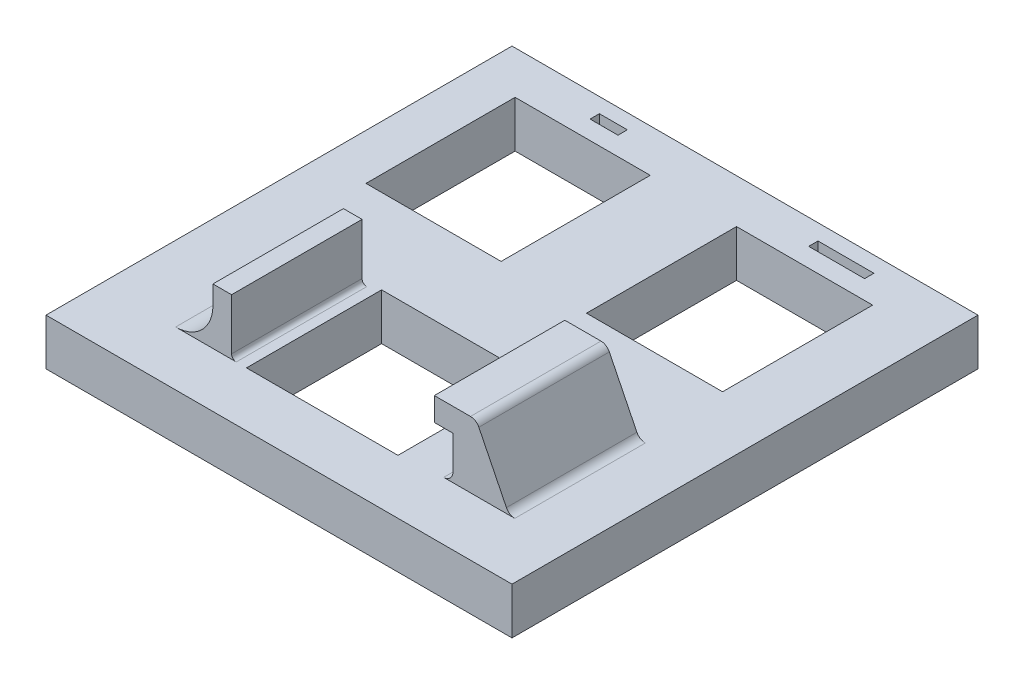
from build123d import *

# Parameters (mm, degrees)
SKETCH1_W           = 50
SKETCH1_H           = 25
BOSS_EXTRUDE1_DEPTH = 5
SKETCH2_W           = 14.5
SKETCH2_H           = 16
CUT_EXTRUDE1_DEPTH  = 5
SKETCH3_W           = 14.6
SKETCH3_H           = 16.1
CUT_EXTRUDE2_DEPTH  = 5
SKETCH5_W           = 3
SKETCH5_H           = 1
SKETCH5_W_2         = 6
CUT_EXTRUDE3_DEPTH  = 1
SKETCH6_W           = 50
SKETCH6_H           = 25
BOSS_EXTRUDE2_DEPTH = 5
SKETCH7_W           = 16.25
SKETCH7_H           = 14.5
CUT_EXTRUDE4_DEPTH  = 4
SKETCH8_W           = 14.75
SKETCH8_H           = 14.5
CUT_EXTRUDE5_DEPTH  = 1
SKETCH9_W           = 2.5
SKETCH9_H           = 14
BOSS_EXTRUDE3_DEPTH = 4.6
SKETCH10_W          = 5
SKETCH10_H          = 14
BOSS_EXTRUDE4_DEPTH = 2.5
BOSS_EXTRUDE5_DEPTH = 14
FILLET1_R           = 1
SKETCH12_W          = 2
SKETCH12_H          = 14
BOSS_EXTRUDE6_DEPTH = 6
FILLET2_R           = 4
FILLET3_R           = 1
FILLET4_R           = 0.5
SKETCH13_W          = 14
SKETCH13_H          = 2.5
CUT_EXTRUDE6_DEPTH  = 0.5


with BuildPart() as part:
    # Sketch1 → Boss-Extrude1 (new body)
    with BuildSketch(Plane(origin=(0, 0, 0), x_dir=(1, 0, 0), z_dir=(0, 1, 0))):
        Rectangle(SKETCH1_W, SKETCH1_H)
    extrude(amount=BOSS_EXTRUDE1_DEPTH)

    # Sketch2 → Cut-Extrude1 (cut)
    with BuildSketch(Plane(origin=(0, 5, 0), x_dir=(1, 0, 0), z_dir=(0, 1, 0))):
        with Locations((-12.821632497, -0.096290121)):
            Rectangle(SKETCH2_W, SKETCH2_H)
    extrude(amount=-CUT_EXTRUDE1_DEPTH, mode=Mode.SUBTRACT)

    # Sketch3 → Cut-Extrude2 (cut)
    with BuildSketch(Plane(origin=(0, 5, 0), x_dir=(1, 0, 0), z_dir=(0, 1, 0))):
        with Locations((11.118853314, -0.27633095)):
            Rectangle(SKETCH3_W, SKETCH3_H)
    extrude(amount=-CUT_EXTRUDE2_DEPTH, mode=Mode.SUBTRACT)

    # Sketch5 → Cut-Extrude3 (cut)
    with BuildSketch(Plane(origin=(0, 5, 0), x_dir=(1, 0, 0), z_dir=(0, 1, 0))):
        with Locations((-12.529830787, 10.403858803)):
            Rectangle(SKETCH5_W, SKETCH5_H)
        with Locations((12.528710417, 10.30293358)):
            Rectangle(SKETCH5_W_2, SKETCH5_H)
    extrude(amount=-CUT_EXTRUDE3_DEPTH, mode=Mode.SUBTRACT)

    # Sketch6 → Boss-Extrude2 (add)
    with BuildSketch(Plane(origin=(0, 0, 0), x_dir=(1, 0, 0), z_dir=(0, 1, 0))):
        with Locations((0, -25)):
            Rectangle(SKETCH6_W, SKETCH6_H)
    extrude(amount=BOSS_EXTRUDE2_DEPTH)

    # Sketch7 → Cut-Extrude4 (cut)
    with BuildSketch(Plane(origin=(0, 5, 0), x_dir=(1, 0, 0), z_dir=(0, 1, 0))):
        with Locations((-1.214601825, -24.398968546)):
            Rectangle(SKETCH7_W, SKETCH7_H)
    extrude(amount=-CUT_EXTRUDE4_DEPTH, mode=Mode.SUBTRACT)

    # Sketch8 → Cut-Extrude5 (cut)
    with BuildSketch(Plane(origin=(0, 1, 0), x_dir=(1, 0, 0), z_dir=(0, 1, 0))):
        with Locations((-1.964601825, -24.398968546)):
            Rectangle(SKETCH8_W, SKETCH8_H)
    extrude(amount=-CUT_EXTRUDE5_DEPTH, mode=Mode.SUBTRACT)

    # Sketch9 → Boss-Extrude3 (add)
    with BuildSketch(Plane(origin=(0, 5, 0), x_dir=(1, 0, 0), z_dir=(0, 1, 0))):
        with Locations((13.660398175, -24.242407708)):
            Rectangle(SKETCH9_W, SKETCH9_H)
    extrude(amount=BOSS_EXTRUDE3_DEPTH)

    # Sketch10 → Boss-Extrude4 (add)
    with BuildSketch(Plane(origin=(0, 9.6, 0), x_dir=(1, 0, 0), z_dir=(0, 1, 0))):
        with Locations((12.410398175, -24.242407708)):
            Rectangle(SKETCH10_W, SKETCH10_H)
    extrude(amount=BOSS_EXTRUDE4_DEPTH)

    # Sketch11 → Boss-Extrude5 (add)
    with BuildSketch(Plane.XY.offset(31.242407708)):
        Polygon((14.910398175, 5), (18.418853314, 5), (14.910398175, 12.1), align=None)
    extrude(amount=-BOSS_EXTRUDE5_DEPTH)

    # Fillet1
    fillet1_edges = [part.edges().sort_by_distance(p)[0] for p in [
        (14.910398175, 12.1, 24.242407708),
        (18.418853314, 5, 24.242407708),
    ]]
    fillet(fillet1_edges, radius=FILLET1_R)

    # Sketch12 → Boss-Extrude6 (add)
    with BuildSketch(Plane(origin=(0, 5, 0), x_dir=(1, 0, 0), z_dir=(0, 1, 0))):
        with Locations((-11.939601825, -24.648968546)):
            Rectangle(SKETCH12_W, SKETCH12_H)
    extrude(amount=BOSS_EXTRUDE6_DEPTH)

    # Fillet2
    fillet2_edges = [part.edges().sort_by_distance(p)[0] for p in [
        (-12.939601825, 5, 24.648968546),
    ]]
    fillet(fillet2_edges, radius=FILLET2_R)

    # Fillet3
    fillet3_edges = [part.edges().sort_by_distance(p)[0] for p in [
        (12.410398175, 5, 24.242407708),
    ]]
    fillet(fillet3_edges, radius=FILLET3_R)

    # Fillet4
    fillet4_edges = [part.edges().sort_by_distance(p)[0] for p in [
        (-10.939601825, 5, 24.648968546),
    ]]
    fillet(fillet4_edges, radius=FILLET4_R)

    # Sketch13 → Cut-Extrude6 (cut)
    with BuildSketch(Plane.ZY.offset(-9.910398175)):
        with Locations((24.242407708, 10.85)):
            Rectangle(SKETCH13_W, SKETCH13_H)
    extrude(amount=-CUT_EXTRUDE6_DEPTH, mode=Mode.SUBTRACT)


solid = part.part
